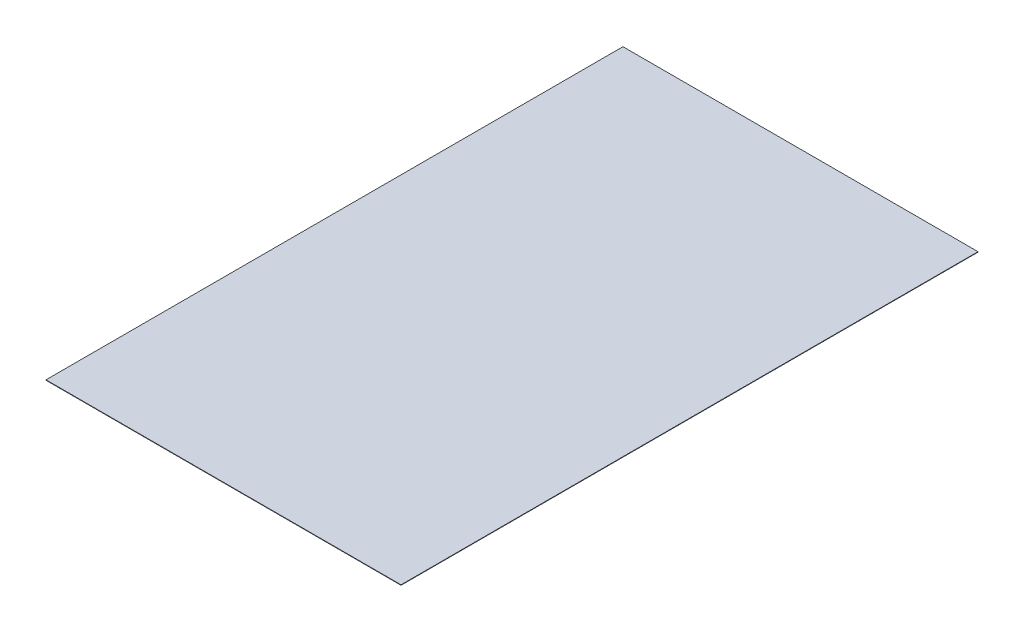
from build123d import *

# Parameters (mm, degrees)
SKETCH_1_W      = 400
SKETCH_1_H      = 650
EXTRUDE_1_DEPTH = 0.5


with BuildPart() as part:
    # 草图1 → 凸台-拉伸1 (new body)
    with BuildSketch(Plane(origin=(0, 0, 0), x_dir=(1, 0, 0), z_dir=(0, 1, 0))):
        with Locations((200, 325)):
            Rectangle(SKETCH_1_W, SKETCH_1_H)
    extrude(amount=EXTRUDE_1_DEPTH)


solid = part.part
